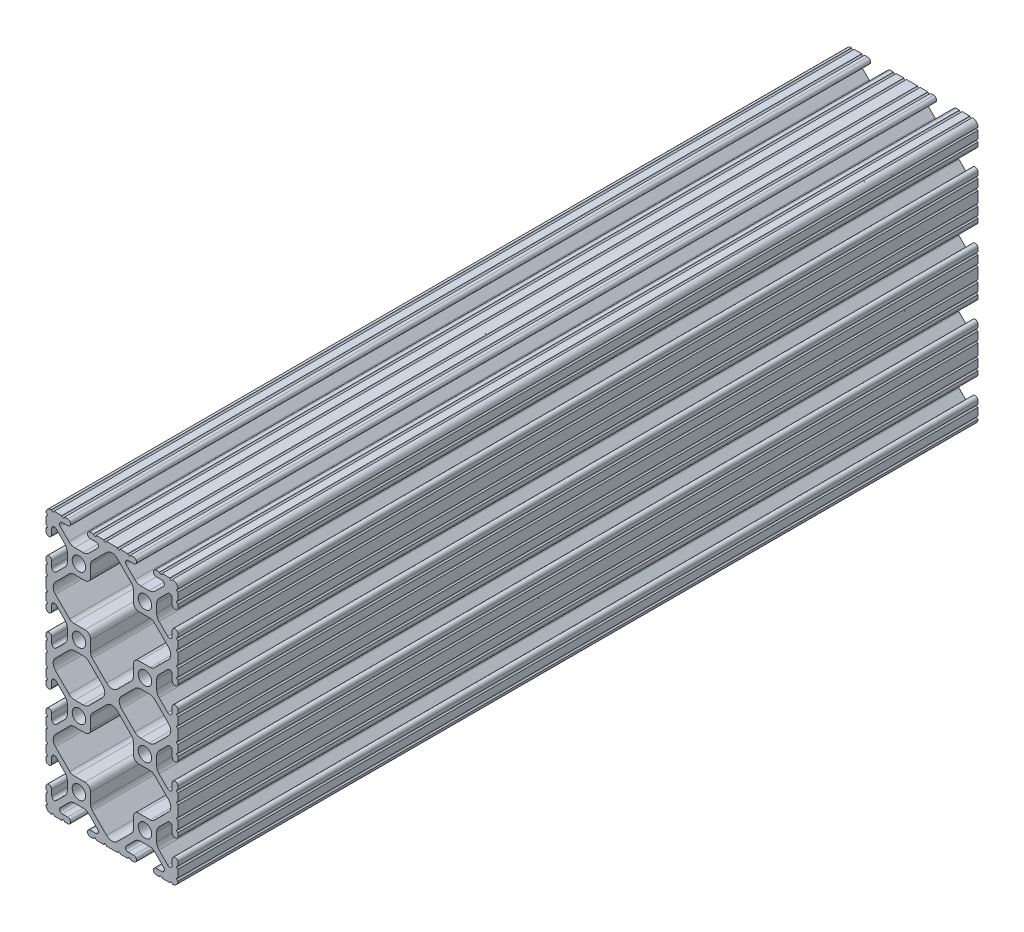
from build123d import *

# Parameters (mm, degrees)
SKETCH1_R      = 2.6035
EXTRUDE1_DEPTH = 307.975


with BuildPart() as part:
    # Sketch1 → Extrude1 (new body)
    with BuildSketch(Plane.XY):
        with BuildLine():
            Line((-12.699984366, 40.2336), (-12.699984366, 35.9664))
            ThreePointArc((-12.699984366, 35.9664), (-12.192, 35.458392183), (-12.7, 34.9504))
            Line((-12.7, 34.9504), (-12.7, 32.004))
            ThreePointArc((-12.7, 32.004), (-12.192, 31.496), (-12.7, 30.988))
            Line((-12.7, 30.988), (-12.7, 29.7434))
            ThreePointArc((-12.7, 29.7434), (-11.5951, 28.6385), (-10.4902, 29.7434))
            Line((-10.4902, 29.7434), (-10.4902, 31.874256981))
            ThreePointArc((-10.4902, 31.874256981), (-9.863010627, 32.812916821), (-8.755786031, 32.592683991))
            Line((-8.755786031, 32.592683991), (-5.425756348, 29.262714761))
            ThreePointArc((-5.425756348, 29.262714761), (-4.737487999, 28.232663563), (-4.4958, 27.017630353))
            Line((-4.4958, 27.017630353), (-4.4958, 23.782369647))
            ThreePointArc((-4.4958, 23.782369647), (-4.737487999, 22.567336437), (-5.425756348, 21.537285239))
            Line((-5.425756348, 21.537285239), (-8.755786031, 18.207316009))
            ThreePointArc((-8.755786031, 18.207316009), (-9.863010627, 17.987083179), (-10.4902, 18.925743019))
            Line((-10.4902, 18.925743019), (-10.4902, 21.0566))
            ThreePointArc((-10.4902, 21.0566), (-11.5951, 22.1615), (-12.7, 21.0566))
            Line((-12.7, 21.0566), (-12.7, 19.812))
            ThreePointArc((-12.7, 19.812), (-12.192, 19.304), (-12.7, 18.796))
            Line((-12.7, 18.796), (-12.7, 15.8496))
            ThreePointArc((-12.7, 15.8496), (-12.192, 15.341607817), (-12.699984366, 14.8336))
            Line((-12.699984366, 14.8336), (-12.699984366, 10.5664))
            ThreePointArc((-12.699984366, 10.5664), (-12.192, 10.0584), (-12.699984366, 9.5504))
            Line((-12.699984366, 9.5504), (-12.699984366, 6.604))
            ThreePointArc((-12.699984366, 6.604), (-12.192, 6.095992183), (-12.7, 5.588))
            Line((-12.7, 5.588), (-12.7, 4.3434))
            ThreePointArc((-12.7, 4.3434), (-11.5951, 3.2385), (-10.4902, 4.3434))
            Line((-10.4902, 4.3434), (-10.4902, 6.474256981))
            ThreePointArc((-10.4902, 6.474256981), (-9.863010627, 7.412916821), (-8.755786031, 7.192683991))
            Line((-8.755786031, 7.192683991), (-5.425756348, 3.862714761))
            ThreePointArc((-5.425756348, 3.862714761), (-4.737487999, 2.832663563), (-4.4958, 1.617630353))
            Line((-4.4958, 1.617630353), (-4.4958, -1.617630353))
            ThreePointArc((-4.4958, -1.617630353), (-4.737487999, -2.832663563), (-5.425756348, -3.862714761))
            Line((-5.425756348, -3.862714761), (-8.755786031, -7.192683991))
            ThreePointArc((-8.755786031, -7.192683991), (-9.863010627, -7.412916821), (-10.4902, -6.474256981))
            Line((-10.4902, -6.474256981), (-10.4902, -4.3434))
            ThreePointArc((-10.4902, -4.3434), (-11.5951, -3.2385), (-12.7, -4.3434))
            Line((-12.7, -4.3434), (-12.7, -5.588))
            ThreePointArc((-12.7, -5.588), (-12.192, -6.096), (-12.7, -6.604))
            Line((-12.7, -6.604), (-12.7, -9.5504))
            ThreePointArc((-12.7, -9.5504), (-12.192000007, -10.058315768), (-12.699831537, -10.566399972))
            ThreePointArc((-12.699831537, -10.566399972), (-12.082506882, -12.082506882), (-10.566399972, -12.699831537))
            ThreePointArc((-10.566399972, -12.699831537), (-10.058315768, -12.192000007), (-9.5504, -12.7))
            Line((-9.5504, -12.7), (-6.604, -12.7))
            ThreePointArc((-6.604, -12.7), (-6.096, -12.192), (-5.588, -12.7))
            Line((-5.588, -12.7), (-4.3434, -12.7))
            ThreePointArc((-4.3434, -12.7), (-3.2385, -11.5951), (-4.3434, -10.4902))
            Line((-4.3434, -10.4902), (-6.474256981, -10.4902))
            ThreePointArc((-6.474256981, -10.4902), (-7.412916821, -9.863010627), (-7.192683991, -8.755786031))
            Line((-7.192683991, -8.755786031), (-3.862714761, -5.425756348))
            ThreePointArc((-3.862714761, -5.425756348), (-2.832663563, -4.737487999), (-1.617630353, -4.4958))
            Line((-1.617630353, -4.4958), (1.617630353, -4.4958))
            ThreePointArc((1.617630353, -4.4958), (2.832663563, -4.737487999), (3.862714761, -5.425756348))
            Line((3.862714761, -5.425756348), (7.192683991, -8.755786031))
            ThreePointArc((7.192683991, -8.755786031), (7.412916821, -9.863010627), (6.474256981, -10.4902))
            Line((6.474256981, -10.4902), (4.3434, -10.4902))
            ThreePointArc((4.3434, -10.4902), (3.2385, -11.5951), (4.3434, -12.7))
            Line((4.3434, -12.7), (5.588, -12.7))
            ThreePointArc((5.588, -12.7), (6.096, -12.192), (6.604, -12.7))
            Line((6.604, -12.7), (9.5504, -12.7))
            ThreePointArc((9.5504, -12.7), (10.0584, -12.192), (10.5664, -12.7))
            Line((10.5664, -12.7), (14.8336, -12.7))
            ThreePointArc((14.8336, -12.7), (15.3416, -12.192), (15.8496, -12.7))
            Line((15.8496, -12.7), (18.796, -12.7))
            ThreePointArc((18.796, -12.7), (19.304, -12.192), (19.812, -12.7))
            Line((19.812, -12.7), (21.0566, -12.7))
            ThreePointArc((21.0566, -12.7), (22.1615, -11.5951), (21.0566, -10.4902))
            Line((21.0566, -10.4902), (18.925743019, -10.4902))
            ThreePointArc((18.925743019, -10.4902), (17.987083179, -9.863010627), (18.207316009, -8.755786031))
            Line((18.207316009, -8.755786031), (21.537285239, -5.425756348))
            ThreePointArc((21.537285239, -5.425756348), (22.567336437, -4.737487999), (23.782369647, -4.4958))
            Line((23.782369647, -4.4958), (27.017630353, -4.4958))
            ThreePointArc((27.017630353, -4.4958), (28.232663563, -4.737487999), (29.262714761, -5.425756348))
            Line((29.262714761, -5.425756348), (32.592683991, -8.755786031))
            ThreePointArc((32.592683991, -8.755786031), (32.812916821, -9.863010627), (31.874256981, -10.4902))
            Line((31.874256981, -10.4902), (29.7434, -10.4902))
            ThreePointArc((29.7434, -10.4902), (28.6385, -11.5951), (29.7434, -12.7))
            Line((29.7434, -12.7), (30.988, -12.7))
            ThreePointArc((30.988, -12.7), (31.496, -12.192), (32.004, -12.7))
            Line((32.004, -12.7), (34.9504, -12.7))
            ThreePointArc((34.9504, -12.7), (35.458315768, -12.192000007), (35.966399972, -12.699831537))
            ThreePointArc((35.966399972, -12.699831537), (37.482506882, -12.082506882), (38.099831537, -10.566399972))
            ThreePointArc((38.099831537, -10.566399972), (37.592000007, -10.058315768), (38.1, -9.5504))
            Line((38.1, -9.5504), (38.1, -6.604))
            ThreePointArc((38.1, -6.604), (37.592, -6.096), (38.1, -5.588))
            Line((38.1, -5.588), (38.1, -4.3434))
            ThreePointArc((38.1, -4.3434), (36.9951, -3.2385), (35.8902, -4.3434))
            Line((35.8902, -4.3434), (35.8902, -6.474256981))
            ThreePointArc((35.8902, -6.474256981), (35.263010627, -7.412916821), (34.155786031, -7.192683991))
            Line((34.155786031, -7.192683991), (30.825756348, -3.862714761))
            ThreePointArc((30.825756348, -3.862714761), (30.137487999, -2.832663563), (29.8958, -1.617630353))
            Line((29.8958, -1.617630353), (29.8958, 1.617630353))
            ThreePointArc((29.8958, 1.617630353), (30.137487999, 2.832663563), (30.825756348, 3.862714761))
            Line((30.825756348, 3.862714761), (34.155786031, 7.192683991))
            ThreePointArc((34.155786031, 7.192683991), (35.263010627, 7.412916821), (35.8902, 6.474256981))
            Line((35.8902, 6.474256981), (35.8902, 4.3434))
            ThreePointArc((35.8902, 4.3434), (36.9951, 3.2385), (38.1, 4.3434))
            Line((38.1, 4.3434), (38.1, 5.588))
            ThreePointArc((38.1, 5.588), (37.592, 6.096), (38.1, 6.604))
            Line((38.1, 6.604), (38.1, 9.5504))
            ThreePointArc((38.1, 9.5504), (37.592, 10.058392183), (38.099984366, 10.5664))
            Line((38.099984366, 10.5664), (38.099984366, 14.8336))
            ThreePointArc((38.099984366, 14.8336), (37.592, 15.3416), (38.099984366, 15.8496))
            Line((38.099984366, 15.8496), (38.099984366, 18.796))
            ThreePointArc((38.099984366, 18.796), (37.592, 19.304007817), (38.1, 19.812))
            Line((38.1, 19.812), (38.1, 21.0566))
            ThreePointArc((38.1, 21.0566), (36.9951, 22.1615), (35.8902, 21.0566))
            Line((35.8902, 21.0566), (35.8902, 18.925743019))
            ThreePointArc((35.8902, 18.925743019), (35.263010627, 17.987083179), (34.155786031, 18.207316009))
            Line((34.155786031, 18.207316009), (30.825756348, 21.537285239))
            ThreePointArc((30.825756348, 21.537285239), (30.137487999, 22.567336437), (29.8958, 23.782369647))
            Line((29.8958, 23.782369647), (29.8958, 27.017630353))
            ThreePointArc((29.8958, 27.017630353), (30.137487999, 28.232663563), (30.825756348, 29.262714761))
            Line((30.825756348, 29.262714761), (34.155786031, 32.592683991))
            ThreePointArc((34.155786031, 32.592683991), (35.263010627, 32.812916821), (35.8902, 31.874256981))
            Line((35.8902, 31.874256981), (35.8902, 29.7434))
            ThreePointArc((35.8902, 29.7434), (36.9951, 28.6385), (38.1, 29.7434))
            Line((38.1, 29.7434), (38.1, 30.988))
            ThreePointArc((38.1, 30.988), (37.592, 31.495992183), (38.099984366, 32.004))
            Line((38.099984366, 32.004), (38.099984366, 34.9504))
            ThreePointArc((38.099984366, 34.9504), (37.592, 35.4584), (38.099984366, 35.9664))
            Line((38.099984366, 35.9664), (38.099984366, 40.2336))
            ThreePointArc((38.099984366, 40.2336), (37.592, 40.7416), (38.099984366, 41.2496))
            Line((38.099984366, 41.2496), (38.099984366, 44.196))
            ThreePointArc((38.099984366, 44.196), (37.592, 44.704007817), (38.1, 45.212))
            Line((38.1, 45.212), (38.1, 46.4566))
            ThreePointArc((38.1, 46.4566), (36.9951, 47.5615), (35.8902, 46.4566))
            Line((35.8902, 46.4566), (35.8902, 44.325743019))
            ThreePointArc((35.8902, 44.325743019), (35.263010627, 43.387083179), (34.155786031, 43.607316009))
            Line((34.155786031, 43.607316009), (30.825756348, 46.937285239))
            ThreePointArc((30.825756348, 46.937285239), (30.137487999, 47.967336437), (29.8958, 49.182369647))
            Line((29.8958, 49.182369647), (29.8958, 52.417630353))
            ThreePointArc((29.8958, 52.417630353), (30.137487999, 53.632663563), (30.825756348, 54.662714761))
            Line((30.825756348, 54.662714761), (34.155786031, 57.992683991))
            ThreePointArc((34.155786031, 57.992683991), (35.263010627, 58.212916821), (35.8902, 57.274256981))
            Line((35.8902, 57.274256981), (35.8902, 55.1434))
            ThreePointArc((35.8902, 55.1434), (36.9951, 54.0385), (38.1, 55.1434))
            Line((38.1, 55.1434), (38.1, 56.388))
            ThreePointArc((38.1, 56.388), (37.592, 56.896), (38.1, 57.404))
            Line((38.1, 57.404), (38.1, 60.3504))
            ThreePointArc((38.1, 60.3504), (37.592, 60.858392183), (38.099984366, 61.3664))
            Line((38.099984366, 61.3664), (38.099984366, 65.6336))
            ThreePointArc((38.099984366, 65.6336), (37.592, 66.141607817), (38.1, 66.6496))
            Line((38.1, 66.6496), (38.1, 69.596))
            ThreePointArc((38.1, 69.596), (37.592, 70.104), (38.1, 70.612))
            Line((38.1, 70.612), (38.1, 71.8566))
            ThreePointArc((38.1, 71.8566), (36.9951, 72.9615), (35.8902, 71.8566))
            Line((35.8902, 71.8566), (35.8902, 69.725743019))
            ThreePointArc((35.8902, 69.725743019), (35.263010627, 68.787083179), (34.155786031, 69.007316009))
            Line((34.155786031, 69.007316009), (30.825756348, 72.337285239))
            ThreePointArc((30.825756348, 72.337285239), (30.137487999, 73.367336437), (29.8958, 74.582369647))
            Line((29.8958, 74.582369647), (29.8958, 77.817630353))
            ThreePointArc((29.8958, 77.817630353), (30.137487999, 79.032663563), (30.825756348, 80.062714761))
            Line((30.825756348, 80.062714761), (34.155786031, 83.392683991))
            ThreePointArc((34.155786031, 83.392683991), (35.263010627, 83.612916821), (35.8902, 82.674256981))
            Line((35.8902, 82.674256981), (35.8902, 80.5434))
            ThreePointArc((35.8902, 80.5434), (36.9951, 79.4385), (38.1, 80.5434))
            Line((38.1, 80.5434), (38.1, 81.788))
            ThreePointArc((38.1, 81.788), (37.592, 82.296), (38.1, 82.804))
            Line((38.1, 82.804), (38.1, 85.7504))
            ThreePointArc((38.1, 85.7504), (37.592000007, 86.258315768), (38.099831537, 86.766399972))
            ThreePointArc((38.099831537, 86.766399972), (37.482506882, 88.282506882), (35.966399972, 88.899831537))
            ThreePointArc((35.966399972, 88.899831537), (35.458315768, 88.392000007), (34.9504, 88.9))
            Line((34.9504, 88.9), (32.004, 88.9))
            ThreePointArc((32.004, 88.9), (31.496, 88.392), (30.988, 88.9))
            Line((30.988, 88.9), (29.7434, 88.9))
            ThreePointArc((29.7434, 88.9), (28.6385, 87.7951), (29.7434, 86.6902))
            Line((29.7434, 86.6902), (31.874256981, 86.6902))
            ThreePointArc((31.874256981, 86.6902), (32.812916821, 86.063010627), (32.592683991, 84.955786031))
            Line((32.592683991, 84.955786031), (29.262714761, 81.625756348))
            ThreePointArc((29.262714761, 81.625756348), (28.232663563, 80.937487999), (27.017630353, 80.6958))
            Line((27.017630353, 80.6958), (23.782369647, 80.6958))
            ThreePointArc((23.782369647, 80.6958), (22.567336437, 80.937487999), (21.537285239, 81.625756348))
            Line((21.537285239, 81.625756348), (18.207316009, 84.955786031))
            ThreePointArc((18.207316009, 84.955786031), (17.987083179, 86.063010627), (18.925743019, 86.6902))
            Line((18.925743019, 86.6902), (21.0566, 86.6902))
            ThreePointArc((21.0566, 86.6902), (22.1615, 87.7951), (21.0566, 88.9))
            Line((21.0566, 88.9), (19.812, 88.9))
            ThreePointArc((19.812, 88.9), (19.304, 88.392), (18.796, 88.9))
            Line((18.796, 88.9), (15.8496, 88.9))
            ThreePointArc((15.8496, 88.9), (15.3416, 88.392), (14.8336, 88.9))
            Line((14.8336, 88.9), (10.5664, 88.9))
            ThreePointArc((10.5664, 88.9), (10.0584, 88.392), (9.5504, 88.9))
            Line((9.5504, 88.9), (6.604, 88.9))
            ThreePointArc((6.604, 88.9), (6.096, 88.392), (5.588, 88.9))
            Line((5.588, 88.9), (4.3434, 88.9))
            ThreePointArc((4.3434, 88.9), (3.2385, 87.7951), (4.3434, 86.6902))
            Line((4.3434, 86.6902), (6.474256981, 86.6902))
            ThreePointArc((6.474256981, 86.6902), (7.412916821, 86.063010627), (7.192683991, 84.955786031))
            Line((7.192683991, 84.955786031), (3.862714761, 81.625756348))
            ThreePointArc((3.862714761, 81.625756348), (2.832663563, 80.937487999), (1.617630353, 80.6958))
            Line((1.617630353, 80.6958), (-1.617630353, 80.6958))
            ThreePointArc((-1.617630353, 80.6958), (-2.832663563, 80.937487999), (-3.862714761, 81.625756348))
            Line((-3.862714761, 81.625756348), (-7.192683991, 84.955786031))
            ThreePointArc((-7.192683991, 84.955786031), (-7.412916821, 86.063010627), (-6.474256981, 86.6902))
            Line((-6.474256981, 86.6902), (-4.3434, 86.6902))
            ThreePointArc((-4.3434, 86.6902), (-3.2385, 87.7951), (-4.3434, 88.9))
            Line((-4.3434, 88.9), (-5.588, 88.9))
            ThreePointArc((-5.588, 88.9), (-6.096, 88.392), (-6.604, 88.9))
            Line((-6.604, 88.9), (-9.5504, 88.9))
            ThreePointArc((-9.5504, 88.9), (-10.058315768, 88.392000007), (-10.566399972, 88.899831537))
            ThreePointArc((-10.566399972, 88.899831537), (-12.082506882, 88.282506882), (-12.699831537, 86.766399972))
            ThreePointArc((-12.699831537, 86.766399972), (-12.192000007, 86.258315768), (-12.7, 85.7504))
            Line((-12.7, 85.7504), (-12.7, 82.804))
            ThreePointArc((-12.7, 82.804), (-12.192, 82.296), (-12.7, 81.788))
            Line((-12.7, 81.788), (-12.7, 80.5434))
            ThreePointArc((-12.7, 80.5434), (-11.5951, 79.4385), (-10.4902, 80.5434))
            Line((-10.4902, 80.5434), (-10.4902, 82.674256981))
            ThreePointArc((-10.4902, 82.674256981), (-9.863010627, 83.612916821), (-8.755786031, 83.392683991))
            Line((-8.755786031, 83.392683991), (-5.425756348, 80.062714761))
            ThreePointArc((-5.425756348, 80.062714761), (-4.737487999, 79.032663563), (-4.4958, 77.817630353))
            Line((-4.4958, 77.817630353), (-4.4958, 74.582369647))
            ThreePointArc((-4.4958, 74.582369647), (-4.737487999, 73.367336437), (-5.425756348, 72.337285239))
            Line((-5.425756348, 72.337285239), (-8.755786031, 69.007316009))
            ThreePointArc((-8.755786031, 69.007316009), (-9.863010627, 68.787083179), (-10.4902, 69.725743019))
            Line((-10.4902, 69.725743019), (-10.4902, 71.8566))
            ThreePointArc((-10.4902, 71.8566), (-11.5951, 72.9615), (-12.7, 71.8566))
            Line((-12.7, 71.8566), (-12.7, 70.612))
            ThreePointArc((-12.7, 70.612), (-12.192, 70.104), (-12.7, 69.596))
            Line((-12.7, 69.596), (-12.7, 66.6496))
            ThreePointArc((-12.7, 66.6496), (-12.192, 66.141607817), (-12.699984366, 65.6336))
            Line((-12.699984366, 65.6336), (-12.699984366, 61.3664))
            ThreePointArc((-12.699984366, 61.3664), (-12.192, 60.858392183), (-12.7, 60.3504))
            Line((-12.7, 60.3504), (-12.7, 57.404))
            ThreePointArc((-12.7, 57.404), (-12.192, 56.896), (-12.7, 56.388))
            Line((-12.7, 56.388), (-12.7, 55.1434))
            ThreePointArc((-12.7, 55.1434), (-11.5951, 54.0385), (-10.4902, 55.1434))
            Line((-10.4902, 55.1434), (-10.4902, 57.274256981))
            ThreePointArc((-10.4902, 57.274256981), (-9.863010627, 58.212916821), (-8.755786031, 57.992683991))
            Line((-8.755786031, 57.992683991), (-5.425756348, 54.662714761))
            ThreePointArc((-5.425756348, 54.662714761), (-4.737487999, 53.632663563), (-4.4958, 52.417630353))
            Line((-4.4958, 52.417630353), (-4.4958, 49.182369647))
            ThreePointArc((-4.4958, 49.182369647), (-4.737487999, 47.967336437), (-5.425756348, 46.937285239))
            Line((-5.425756348, 46.937285239), (-8.755786031, 43.607316009))
            ThreePointArc((-8.755786031, 43.607316009), (-9.863010627, 43.387083179), (-10.4902, 44.325743019))
            Line((-10.4902, 44.325743019), (-10.4902, 46.4566))
            ThreePointArc((-10.4902, 46.4566), (-11.5951, 47.5615), (-12.7, 46.4566))
            Line((-12.7, 46.4566), (-12.7, 45.212))
            ThreePointArc((-12.7, 45.212), (-12.192, 44.704), (-12.7, 44.196))
            Line((-12.7, 44.196), (-12.7, 41.2496))
            ThreePointArc((-12.7, 41.2496), (-12.192, 40.741607817), (-12.699984366, 40.2336))
        make_face()
        with Locations((25.4, 76.2)):
            Circle(SKETCH1_R, mode=Mode.SUBTRACT)
        with Locations((0, 76.2)):
            Circle(SKETCH1_R, mode=Mode.SUBTRACT)
        with Locations((25.4, 50.8)):
            Circle(SKETCH1_R, mode=Mode.SUBTRACT)
        with Locations((0, 50.8)):
            Circle(SKETCH1_R, mode=Mode.SUBTRACT)
        with Locations((25.4, 0)):
            Circle(SKETCH1_R, mode=Mode.SUBTRACT)
        Circle(SKETCH1_R, mode=Mode.SUBTRACT)
        with Locations((25.4, 25.4)):
            Circle(SKETCH1_R, mode=Mode.SUBTRACT)
        with Locations((0, 25.4)):
            Circle(SKETCH1_R, mode=Mode.SUBTRACT)
        with BuildLine():
            Line((2.286, 55.2958), (-2.018378203, 55.2958))
            ThreePointArc((-2.018378203, 55.2958), (-2.864022786, 55.464007171), (-3.580928584, 55.943021252))
            Line((-3.580928584, 55.943021252), (-9.072529371, 61.434522344))
            ThreePointArc((-9.072529371, 61.434522344), (-9.928089211, 63.5), (-9.072529371, 65.565477656))
            Line((-9.072529371, 65.565477656), (-3.580928584, 71.056978748))
            ThreePointArc((-3.580928584, 71.056978748), (-2.864022786, 71.535992829), (-2.018378203, 71.7042))
            Line((-2.018378203, 71.7042), (2.286, 71.7042))
            ThreePointArc((2.286, 71.7042), (3.848564565, 72.351435435), (4.4958, 73.914))
            Line((4.4958, 73.914), (4.4958, 78.218378203))
            ThreePointArc((4.4958, 78.218378203), (4.664007171, 79.064022786), (5.143021252, 79.780928584))
            Line((5.143021252, 79.780928584), (10.634522344, 85.272529371))
            ThreePointArc((10.634522344, 85.272529371), (12.7, 86.128089211), (14.765477656, 85.272529371))
            Line((14.765477656, 85.272529371), (20.256978748, 79.780928584))
            ThreePointArc((20.256978748, 79.780928584), (20.735992829, 79.064022786), (20.9042, 78.218378203))
            Line((20.9042, 78.218378203), (20.9042, 73.914))
            ThreePointArc((20.9042, 73.914), (21.551435435, 72.351435435), (23.114, 71.7042))
            Line((23.114, 71.7042), (27.418378203, 71.7042))
            ThreePointArc((27.418378203, 71.7042), (28.264022786, 71.535992829), (28.980928584, 71.056978748))
            Line((28.980928584, 71.056978748), (34.472529371, 65.565477656))
            ThreePointArc((34.472529371, 65.565477656), (35.328089211, 63.5), (34.472529371, 61.434522344))
            Line((34.472529371, 61.434522344), (28.980928584, 55.943021252))
            ThreePointArc((28.980928584, 55.943021252), (28.264022786, 55.464007171), (27.418378203, 55.2958))
            Line((27.418378203, 55.2958), (23.114, 55.2958))
            ThreePointArc((23.114, 55.2958), (21.551435435, 54.648564565), (20.9042, 53.086))
            Line((20.9042, 53.086), (20.9042, 48.781621797))
            ThreePointArc((20.9042, 48.781621797), (20.735992829, 47.935977214), (20.256978748, 47.219071416))
            Line((20.256978748, 47.219071416), (14.765477656, 41.727470629))
            ThreePointArc((14.765477656, 41.727470629), (12.7, 40.871910789), (10.634522344, 41.727470629))
            Line((10.634522344, 41.727470629), (5.143021252, 47.219071416))
            ThreePointArc((5.143021252, 47.219071416), (4.664007171, 47.935977214), (4.4958, 48.781621797))
            Line((4.4958, 48.781621797), (4.4958, 53.086))
            ThreePointArc((4.4958, 53.086), (3.848564565, 54.648564565), (2.286, 55.2958))
        make_face(mode=Mode.SUBTRACT)
        with BuildLine():
            Line((4.4958, 23.114), (4.4958, 27.418378203))
            ThreePointArc((4.4958, 27.418378203), (4.664007171, 28.264022786), (5.143021252, 28.980928584))
            Line((5.143021252, 28.980928584), (10.634522344, 34.472529371))
            ThreePointArc((10.634522344, 34.472529371), (12.7, 35.328089211), (14.765477656, 34.472529371))
            Line((14.765477656, 34.472529371), (20.256978748, 28.980928584))
            ThreePointArc((20.256978748, 28.980928584), (20.735992829, 28.264022786), (20.9042, 27.418378203))
            Line((20.9042, 27.418378203), (20.9042, 23.114))
            ThreePointArc((20.9042, 23.114), (21.551435435, 21.551435435), (23.114, 20.9042))
            Line((23.114, 20.9042), (27.418378203, 20.9042))
            ThreePointArc((27.418378203, 20.9042), (28.264022786, 20.735992829), (28.980928584, 20.256978748))
            Line((28.980928584, 20.256978748), (34.472529371, 14.765477656))
            ThreePointArc((34.472529371, 14.765477656), (35.328089211, 12.7), (34.472529371, 10.634522344))
            Line((34.472529371, 10.634522344), (28.980928584, 5.143021252))
            ThreePointArc((28.980928584, 5.143021252), (28.264022786, 4.664007171), (27.418378203, 4.4958))
            Line((27.418378203, 4.4958), (23.114, 4.4958))
            ThreePointArc((23.114, 4.4958), (21.551435435, 3.848564565), (20.9042, 2.286))
            Line((20.9042, 2.286), (20.9042, -2.018378203))
            ThreePointArc((20.9042, -2.018378203), (20.735992829, -2.864022786), (20.256978748, -3.580928584))
            Line((20.256978748, -3.580928584), (14.765477656, -9.072529371))
            ThreePointArc((14.765477656, -9.072529371), (12.7, -9.928089211), (10.634522344, -9.072529371))
            Line((10.634522344, -9.072529371), (5.143021252, -3.580928584))
            ThreePointArc((5.143021252, -3.580928584), (4.664007171, -2.864022786), (4.4958, -2.018378203))
            Line((4.4958, -2.018378203), (4.4958, 2.286))
            ThreePointArc((4.4958, 2.286), (3.848564565, 3.848564565), (2.286, 4.4958))
            Line((2.286, 4.4958), (-2.018378203, 4.4958))
            ThreePointArc((-2.018378203, 4.4958), (-2.864022786, 4.664007171), (-3.580928584, 5.143021252))
            Line((-3.580928584, 5.143021252), (-9.072529371, 10.634522344))
            ThreePointArc((-9.072529371, 10.634522344), (-9.928089211, 12.7), (-9.072529371, 14.765477656))
            Line((-9.072529371, 14.765477656), (-3.580928584, 20.256978748))
            ThreePointArc((-3.580928584, 20.256978748), (-2.864022786, 20.735992829), (-2.018378203, 20.9042))
            Line((-2.018378203, 20.9042), (2.286, 20.9042))
            ThreePointArc((2.286, 20.9042), (3.848564565, 21.551435435), (4.4958, 23.114))
        make_face(mode=Mode.SUBTRACT)
        with BuildLine():
            Line((27.018584404, 29.8958), (23.782369647, 29.8958))
            ThreePointArc((23.782369647, 29.8958), (22.567336437, 30.137487999), (21.537285239, 30.825756348))
            Line((21.537285239, 30.825756348), (16.328576307, 36.03455984))
            ThreePointArc((16.328576307, 36.03455984), (15.473053963, 38.1), (16.328576307, 40.16544016))
            Line((16.328576307, 40.16544016), (21.537285239, 45.374243652))
            ThreePointArc((21.537285239, 45.374243652), (22.567336437, 46.062512001), (23.782369647, 46.3042))
            Line((23.782369647, 46.3042), (27.018584404, 46.3042))
            ThreePointArc((27.018584404, 46.3042), (28.233590989, 46.06252303), (29.263628056, 45.374284409))
            Line((29.263628056, 45.374284409), (34.472529371, 40.165477656))
            ThreePointArc((34.472529371, 40.165477656), (35.328089211, 38.1), (34.472529371, 36.034522344))
            Line((34.472529371, 36.034522344), (29.263628056, 30.825715591))
            ThreePointArc((29.263628056, 30.825715591), (28.233590989, 30.13747697), (27.018584404, 29.8958))
        make_face(mode=Mode.SUBTRACT)
        with BuildLine():
            Line((1.617630353, 29.8958), (-1.618584404, 29.8958))
            ThreePointArc((-1.618584404, 29.8958), (-2.833590989, 30.13747697), (-3.863628056, 30.825715591))
            Line((-3.863628056, 30.825715591), (-9.072529371, 36.034522344))
            ThreePointArc((-9.072529371, 36.034522344), (-9.928089211, 38.1), (-9.072529371, 40.165477656))
            Line((-9.072529371, 40.165477656), (-3.863628056, 45.374284409))
            ThreePointArc((-3.863628056, 45.374284409), (-2.833590989, 46.06252303), (-1.618584404, 46.3042))
            Line((-1.618584404, 46.3042), (1.617630353, 46.3042))
            ThreePointArc((1.617630353, 46.3042), (2.832663563, 46.062512001), (3.862714761, 45.374243652))
            Line((3.862714761, 45.374243652), (9.071423693, 40.16544016))
            ThreePointArc((9.071423693, 40.16544016), (9.926946037, 38.1), (9.071423693, 36.03455984))
            Line((9.071423693, 36.03455984), (3.862714761, 30.825756348))
            ThreePointArc((3.862714761, 30.825756348), (2.832663563, 30.137487999), (1.617630353, 29.8958))
        make_face(mode=Mode.SUBTRACT)
    extrude(amount=-EXTRUDE1_DEPTH)


solid = part.part
